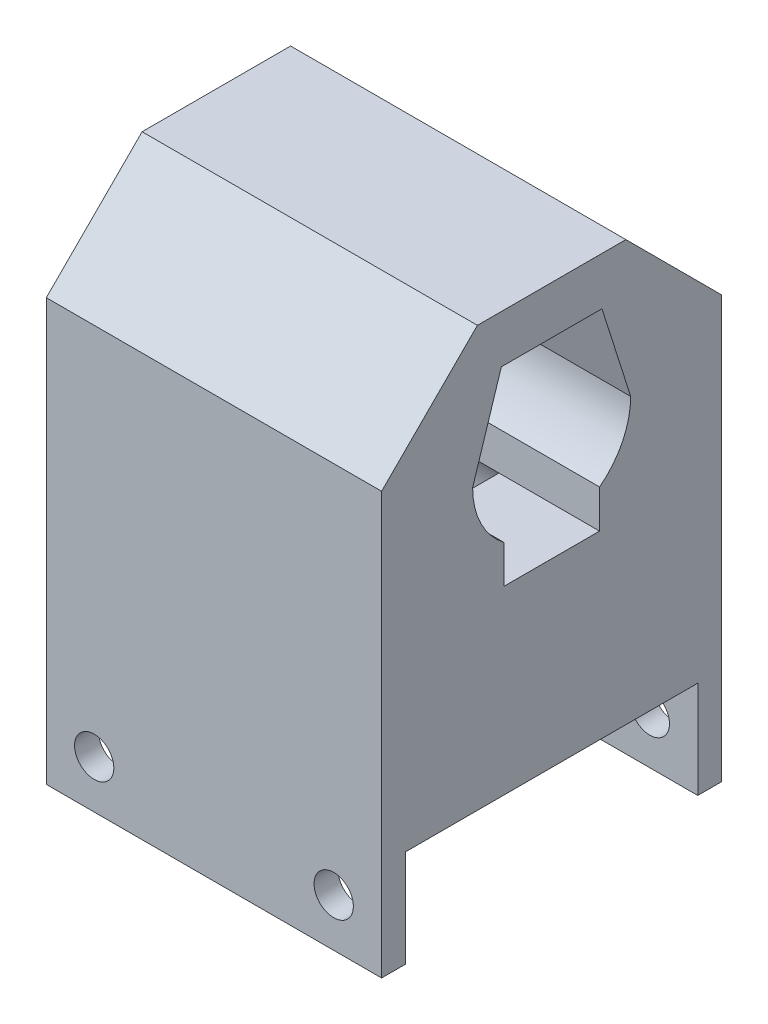
from build123d import *

# Parameters (mm, degrees)
BOSS_EXTRUDE1_DEPTH     = 70
SKETCH3_R               = 4.1
CUT_EXTRUDE2_DEPTH      = 36.5
CUT_EXTRUDE2_DEPTH_BACK = 36.5
BOSS_EXTRUDE2_DEPTH     = 70
BOSS_EXTRUDE5_DEPTH     = 70
BOSS_EXTRUDE6_DEPTH     = 21
CHAMFER1_SIZE           = 20
CHAMFER4_SIZE           = 1


with BuildPart() as part:
    # Sketch1 → Boss-Extrude1 (new body)
    with BuildSketch(Plane(origin=(0, 0, 0), x_dir=(0, 0, -1), z_dir=(1, 0, 0))):
        Polygon((-30.5, 0), (-30.5, 20), (-30.5, 98), (30.5, 98), (30.5, 0), (35.5, 0), (35.5, 108), (-35.5, 108), (-35.5, 0), align=None)
    extrude(amount=-BOSS_EXTRUDE1_DEPTH)

    # Sketch3 → Cut-Extrude2 (cut, two sides)
    with BuildSketch(Plane.XY) as cut_extrude2_sk:
        with Locations((-60, 10)):
            Circle(SKETCH3_R)
        with Locations((-10, 10)):
            Circle(SKETCH3_R)
    extrude(amount=CUT_EXTRUDE2_DEPTH, mode=Mode.SUBTRACT)
    extrude(cut_extrude2_sk.sketch, amount=-CUT_EXTRUDE2_DEPTH_BACK, mode=Mode.SUBTRACT)

    # Sketch4 → Boss-Extrude2 (add)
    with BuildSketch(Plane(origin=(0, 0, 0), x_dir=(0, 0, -1), z_dir=(1, 0, 0))):
        Polygon((-30.5, 98), (-10.5, 98), (-16.5, 79.151), (-30.5, 79.151), align=None)
    boss_extrude2 = extrude(amount=-BOSS_EXTRUDE2_DEPTH)

    # Mirror2: Boss-Extrude2 across plane
    add(boss_extrude2.mirror(Plane.XY))

    # Sketch5 → Boss-Extrude5 (add)
    with BuildSketch(Plane.ZY.offset(70)):
        with BuildLine():
            Line((-30.5, 62.151), (-30.5, 79.151))
            Line((-30.5, 79.151), (-16.5, 79.151))
            ThreePointArc((-16.5, 79.151), (-14.785973083, 71.828090742), (-10, 66.026595252))
            Line((-10, 66.026595252), (-10, 62.151))
            Line((-10, 62.151), (-10, 58.045669043))
            ThreePointArc((-10, 58.045669043), (-19.497965112, 41.023297158), (-9.512195122, 24.282422523))
            Line((-9.512195122, 24.282422523), (-9.512195122, 20.305))
            Line((-9.512195122, 20.305), (-30.5, 20.305))
            Line((-30.5, 20.305), (-30.5, 41.305))
            Line((-30.5, 41.305), (-30.5, 62.151))
        make_face()
    boss_extrude5 = extrude(amount=-BOSS_EXTRUDE5_DEPTH)

    # Mirror3: Boss-Extrude5 across plane
    add(boss_extrude5.mirror(Plane.XY))

    # Sketch6 → Boss-Extrude6 (add)
    with BuildSketch(Plane(origin=(0, 0, 0), x_dir=(0, 0, -1), z_dir=(1, 0, 0))):
        with BuildLine():
            Line((-9.512195122, 20.305), (9.512195122, 20.305))
            Line((9.512195122, 20.305), (9.512195122, 24.282422523))
            ThreePointArc((9.512195122, 24.282422523), (19.497965112, 41.023297158), (10, 58.045669043))
            Line((10, 58.045669043), (-10, 58.045669043))
            ThreePointArc((-10, 58.045669043), (-19.497965112, 41.023297158), (-9.512195122, 24.282422523))
            Line((-9.512195122, 24.282422523), (-9.512195122, 20.305))
        make_face()
    extrude(amount=-BOSS_EXTRUDE6_DEPTH)

    # Mirror1: Boss-Extrude2 across plane
    add(boss_extrude2.mirror(Plane.XY))

    # Chamfer1
    chamfer1_edges = [part.edges().sort_by_distance(p)[0] for p in [
        (-35, 108, 35.5),
        (-35, 108, -35.5),
    ]]
    chamfer(chamfer1_edges, length=CHAMFER1_SIZE)

    # Chamfer4
    chamfer4_edges = [part.edges().sort_by_distance(p)[0] for p in [
        (-70, 41.023297158, 19.497965112),
        (-70, 62.036132147, 10),
        (-70, 71.828090742, 14.785973083),
        (-70, 98, 0),
        (-70, 88.5755, 13.5),
        (-70, 88.5755, -13.5),
        (-70, 41.023297158, -19.497965112),
        (-70, 62.036132147, -10),
        (-70, 71.828090742, -14.785973083),
    ]]
    chamfer(chamfer4_edges, length=CHAMFER4_SIZE)


solid = part.part
